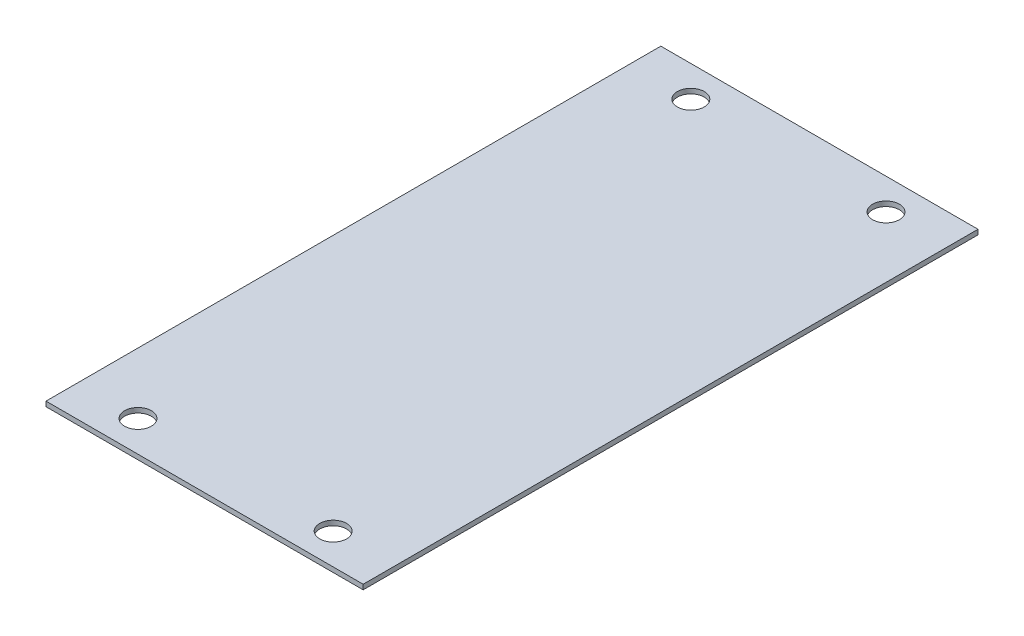
from build123d import *

# Parameters (mm, degrees)
SKETCH1_W           = 130
SKETCH1_H           = 252
SKETCH1_R           = 5.5
BOSS_EXTRUDE1_DEPTH = 2


with BuildPart() as part:
    # Sketch1 → Boss-Extrude1 (new body)
    with BuildSketch(Plane(origin=(0, 0, 0), x_dir=(1, 0, 0), z_dir=(0, 1, 0))):
        Rectangle(SKETCH1_W, SKETCH1_H)
        with Locations((-40, 113.3)):
            Circle(SKETCH1_R, mode=Mode.SUBTRACT)
        with Locations((40, 113.3)):
            Circle(SKETCH1_R, mode=Mode.SUBTRACT)
        with Locations((40, -113.3)):
            Circle(SKETCH1_R, mode=Mode.SUBTRACT)
        with Locations((-40, -113.3)):
            Circle(SKETCH1_R, mode=Mode.SUBTRACT)
    extrude(amount=BOSS_EXTRUDE1_DEPTH)


solid = part.part
